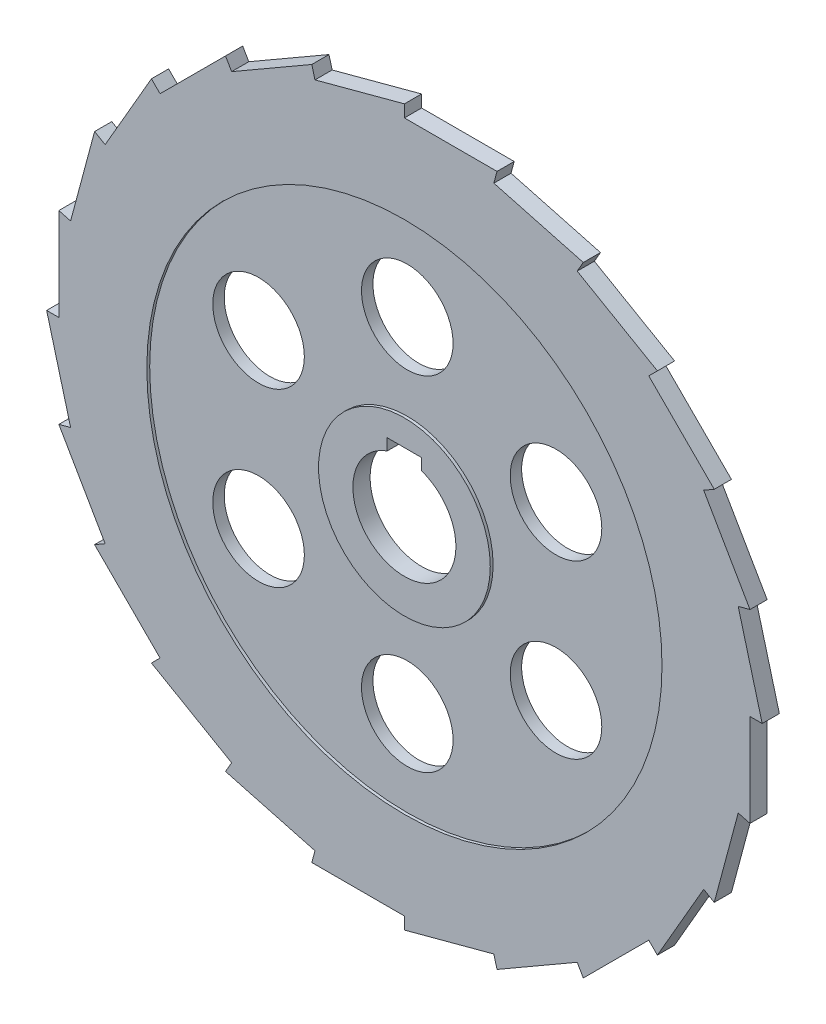
from build123d import *

# Parameters (mm, degrees)
SKETCH1_R           = 45
BOSS_EXTRUDE2_DEPTH = 1.5
SKETCH1_5_R         = 45
SKETCH1_5_R_2       = 8
SKETCH1_5_R_3       = 15
BOSS_EXTRUDE3_DEPTH = 1
SKETCH1_6_R         = 15
BOSS_EXTRUDE4_DEPTH = 1.5


with BuildPart() as part:
    # Sketch1 → Boss-Extrude2 (new, symmetric)
    with BuildSketch(Plane.XY):
        Polygon((0, 60.370364143), (0, 62.5), (-15.625, 58.313293868), (-16.176190319, 60.370364143), (-30.185182072, 52.282268984), (-31.25, 54.126587737), (-42.688293868, 42.688293868), (-44.194173824, 44.194173824), (-52.282268984, 30.185182072), (-54.126587737, 31.25), (-58.313293868, 15.625), (-60.370364143, 16.176190319), (-60.370364143, 0), (-62.5, 0), (-58.313293868, -15.625), (-60.370364143, -16.176190319), (-52.282268984, -30.185182072), (-54.126587737, -31.25), (-42.688293868, -42.688293868), (-44.194173824, -44.194173824), (-30.185182072, -52.282268984), (-31.25, -54.126587737), (-15.625, -58.313293868), (-16.176190319, -60.370364143), (0, -60.370364143), (0, -62.5), (15.625, -58.313293868), (16.176190319, -60.370364143), (30.185182072, -52.282268984), (31.25, -54.126587737), (42.688293868, -42.688293868), (44.194173824, -44.194173824), (52.282268984, -30.185182072), (54.126587737, -31.25), (58.313293868, -15.625), (60.370364143, -16.176190319), (60.370364143, 0), (62.5, 0), (58.313293868, 15.625), (60.370364143, 16.176190319), (52.282268984, 30.185182072), (54.126587737, 31.25), (42.688293868, 42.688293868), (44.194173824, 44.194173824), (30.185182072, 52.282268984), (31.25, 54.126587737), (15.625, 58.313293868), (16.176190319, 60.370364143), align=None)
        Circle(SKETCH1_R, mode=Mode.SUBTRACT)
    extrude(amount=BOSS_EXTRUDE2_DEPTH, both=True)

    # Sketch1_5 → Boss-Extrude3 (add, symmetric)
    with BuildSketch(Plane.XY):
        Circle(SKETCH1_5_R)
        with Locations((-25.980762114, -15)):
            Circle(SKETCH1_5_R_2, mode=Mode.SUBTRACT)
        with Locations((0, -30)):
            Circle(SKETCH1_5_R_2, mode=Mode.SUBTRACT)
        with Locations((25.980762114, -15)):
            Circle(SKETCH1_5_R_2, mode=Mode.SUBTRACT)
        with Locations((-25.980762114, 15)):
            Circle(SKETCH1_5_R_2, mode=Mode.SUBTRACT)
        Circle(SKETCH1_5_R_3, mode=Mode.SUBTRACT)
        with Locations((25.980762114, 15)):
            Circle(SKETCH1_5_R_2, mode=Mode.SUBTRACT)
        with Locations((0, 30)):
            Circle(SKETCH1_5_R_2, mode=Mode.SUBTRACT)
    extrude(amount=BOSS_EXTRUDE3_DEPTH, both=True)

    # Sketch1_6 → Boss-Extrude4 (add, symmetric)
    with BuildSketch(Plane.XY):
        Circle(SKETCH1_6_R)
        with BuildLine():
            ThreePointArc((3, 8.485281374), (0, -9), (-3, 8.485281374))
            Line((-3, 8.485281374), (-3, 10.485281374))
            Line((-3, 10.485281374), (3, 10.485281374))
            Line((3, 10.485281374), (3, 8.485281374))
        make_face(mode=Mode.SUBTRACT)
    extrude(amount=BOSS_EXTRUDE4_DEPTH, both=True)


solid = part.part
